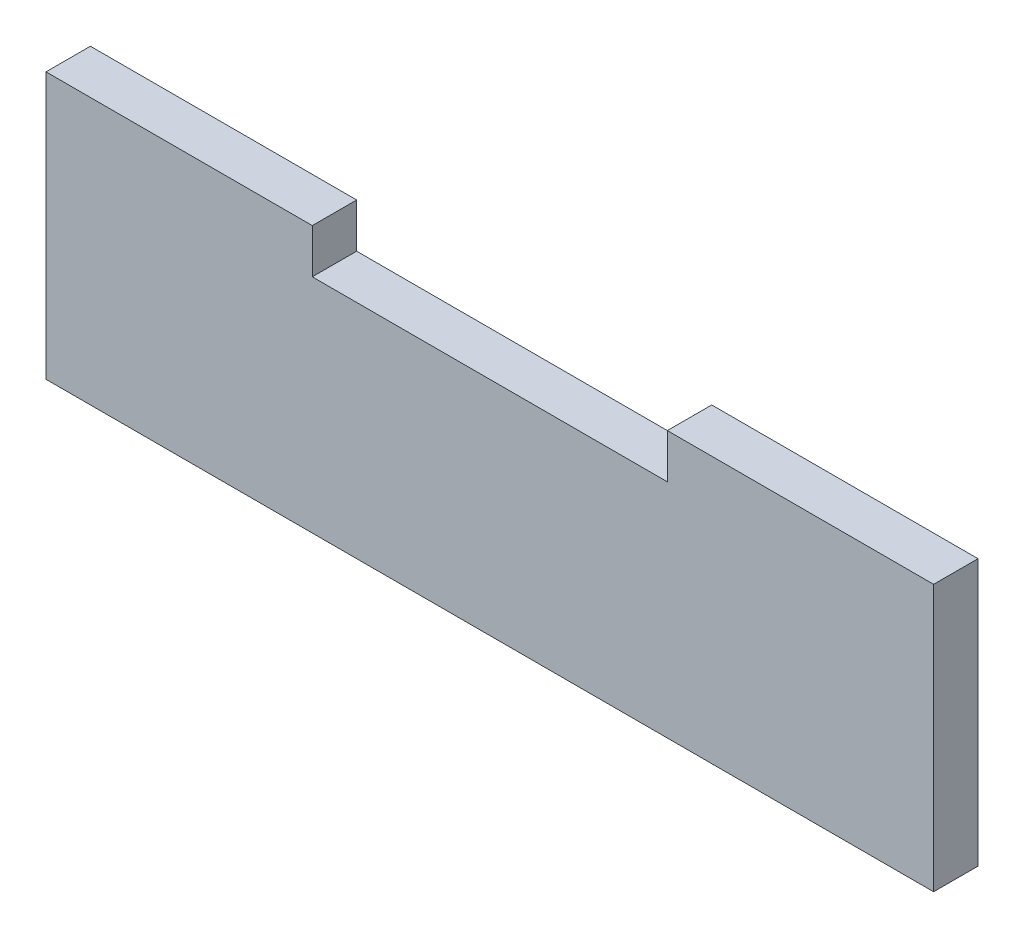
from build123d import *

# Parameters (mm, degrees)
BOSS_EXTRUDE1_DEPTH = 5


with BuildPart() as part:
    # Sketch1 → Boss-Extrude1 (new body)
    with BuildSketch(Plane.XY):
        Polygon((-50, -10.527650376), (50, -10.527650376), (50, 19.472349624), (20, 19.472349624), (20, 14.472349624), (-20, 14.472349624), (-20, 19.472349624), (-50, 19.472349624), align=None)
    extrude(amount=BOSS_EXTRUDE1_DEPTH)


solid = part.part
